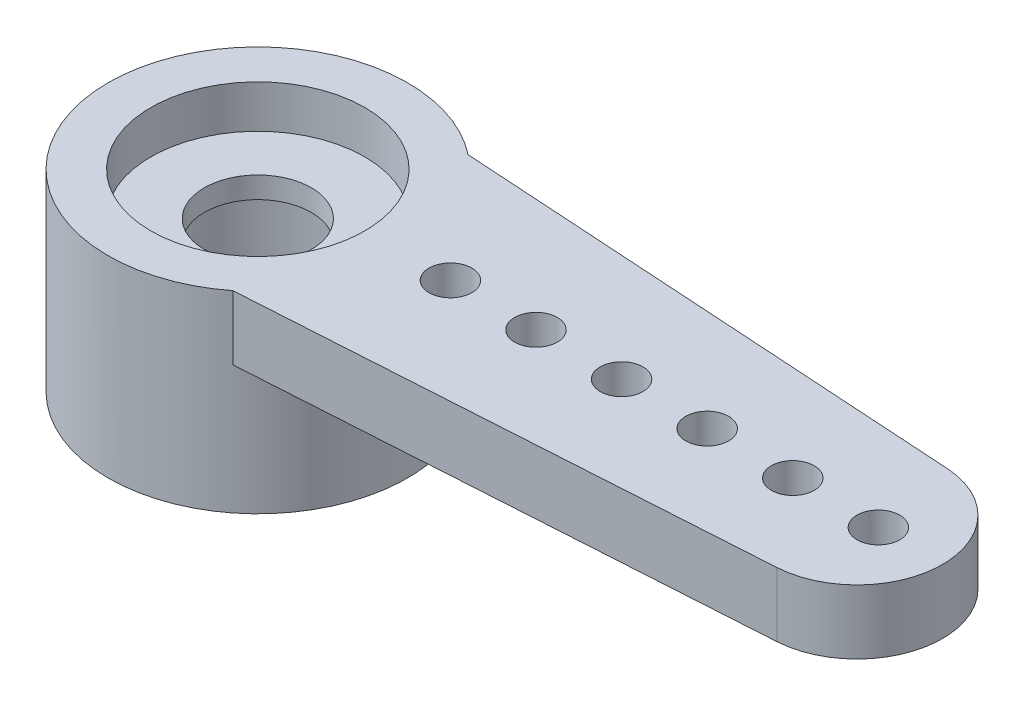
from build123d import *

# Parameters (mm, degrees)
SKETCH1_R           = 3.5
BOSS_EXTRUDE1_DEPTH = 4.5
SKETCH2_R           = 2.5
CUT_EXTRUDE1_DEPTH  = 1
SKETCH3_R           = 2.5
CUT_EXTRUDE2_DEPTH  = 3
SKETCH4_R           = 1.25
CUT_EXTRUDE3_DEPTH  = 4.5
BOSS_EXTRUDE2_DEPTH = 1.5
SKETCH6_R           = 0.5
CUT_EXTRUDE4_DEPTH  = 5.5


with BuildPart() as part:
    # Sketch1 → Boss-Extrude1 (new body)
    with BuildSketch(Plane(origin=(0, 0, 0), x_dir=(1, 0, 0), z_dir=(0, 1, 0))):
        Circle(SKETCH1_R)
    extrude(amount=BOSS_EXTRUDE1_DEPTH)

    # Sketch2 → Cut-Extrude1 (cut)
    with BuildSketch(Plane(origin=(0, 4.5, 0), x_dir=(1, 0, 0), z_dir=(0, 1, 0))):
        Circle(SKETCH2_R)
    extrude(amount=-CUT_EXTRUDE1_DEPTH, mode=Mode.SUBTRACT)

    # Sketch3 → Cut-Extrude2 (cut)
    with BuildSketch(Plane.XZ):
        Circle(SKETCH3_R)
    extrude(amount=-CUT_EXTRUDE2_DEPTH, mode=Mode.SUBTRACT)

    # Sketch4 → Cut-Extrude3 (cut, through all)
    with BuildSketch(Plane(origin=(0, 3.5, 0), x_dir=(1, 0, 0), z_dir=(0, 1, 0))):
        Circle(SKETCH4_R)
    extrude(amount=-CUT_EXTRUDE3_DEPTH, mode=Mode.SUBTRACT)

    # Sketch5 → Boss-Extrude2 (add)
    with BuildSketch(Plane(origin=(0, 4.5, 0), x_dir=(1, 0, 0), z_dir=(0, 1, 0))):
        with BuildLine():
            Line((2.165063509, 2.75), (14.125822824, 1.99603823))
            ThreePointArc((14.125822824, 1.99603823), (16, 0), (14.125822824, -1.99603823))
            Line((14.125822824, -1.99603823), (2.165063509, -2.75))
            ThreePointArc((2.165063509, -2.75), (3.5, 0), (2.165063509, 2.75))
        make_face()
    extrude(amount=-BOSS_EXTRUDE2_DEPTH)

    # Sketch6 → Cut-Extrude4 (cut, through all)
    with BuildSketch(Plane(origin=(0, 4.5, 0), x_dir=(1, 0, 0), z_dir=(0, 1, 0))):
        with Locations((4.5, 0)):
            Circle(SKETCH6_R)
        with Locations((6.5, 0)):
            Circle(SKETCH6_R)
        with Locations((8.5, 0)):
            Circle(SKETCH6_R)
        with Locations((10.5, 0)):
            Circle(SKETCH6_R)
        with Locations((12.5, 0)):
            Circle(SKETCH6_R)
        with Locations((14.5, 0)):
            Circle(SKETCH6_R)
    extrude(amount=-CUT_EXTRUDE4_DEPTH, mode=Mode.SUBTRACT)


solid = part.part
